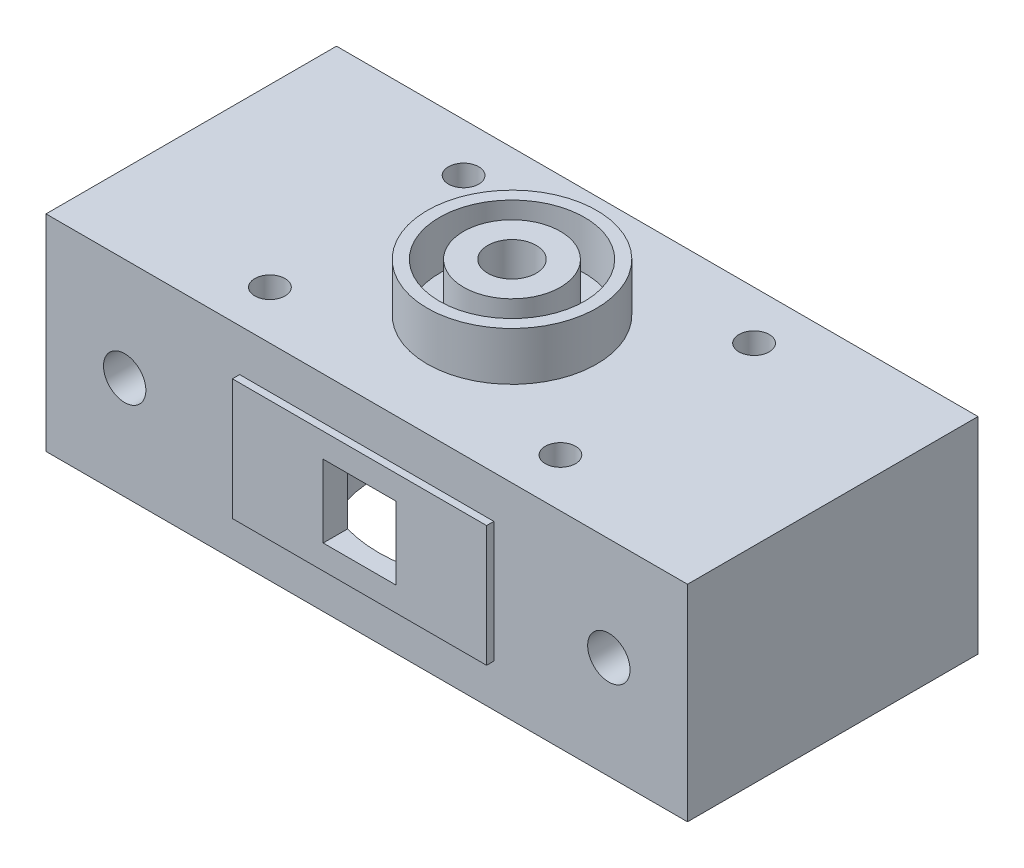
from build123d import *

# Parameters (mm, degrees)
SKETCH_1_R          = 1.75
EXTRUDE_1_DEPTH     = 12
SKETCH_3_R          = 2
CUT_EXTRUDE_1_DEPTH = 18
SKETCH_4_W          = 22.4
SKETCH_4_H          = 14.3
SKETCH_4_W_2        = 6
SKETCH_4_H_2        = 6
EXTRUDE_2_DEPTH     = 1.2
SKETCH_5_W          = 21
SKETCH_5_H          = 10
SKETCH_5_W_2        = 6
SKETCH_5_H_2        = 6
EXTRUDE_3_DEPTH     = 0.6
SKETCH_14_W         = 24.4
SKETCH_14_H         = 23.6
EXTRUDE_6_DEPTH     = 14.3
CUT_EXTRUDE_START   = 2.7
SKETCH_12_R         = 11
CUT_EXTRUDE_6_DEPTH = 14.3
SKETCH_15_W         = 6
SKETCH_15_H         = 6
CUT_EXTRUDE_7_DEPTH = 25.4
SKETCH_6_R          = 7
SKETCH_6_R_2        = 6
SKETCH_6_R_3        = 4
SKETCH_6_R_4        = 2
EXTRUDE_4_DEPTH     = 4
M3X0_51_D           = 2.5
M3X0_51_DEPTH       = 11.5
M3X0_51_TIP         = 0.751075774


with BuildPart() as part:
    # Sketch 1 → Extrude 1 (new body, symmetric)
    with BuildSketch(Plane.XY):
        Polygon((11.2, -17), (11.2, -2.7), (0, -2.7), (0, 0), (26.5, 0), (26.5, -17), align=None)
        with Locations((20, -8.5)):
            Circle(SKETCH_1_R, mode=Mode.SUBTRACT)
    extrude_1 = extrude(amount=EXTRUDE_1_DEPTH, both=True)

    # Mirror 1: Extrude 1 across plane
    add(extrude_1.mirror(Plane(origin=(0, -2.7, -12), x_dir=(0, 0, 1), z_dir=(-1, 0, 0))))

    # Sketch 3 → Cut-Extrude 1 (cut, through all)
    with BuildSketch(Plane(origin=(0, 0, 0), x_dir=(1, 0, 0), z_dir=(0, 1, 0))):
        Circle(SKETCH_3_R)
    extrude(amount=-CUT_EXTRUDE_1_DEPTH, mode=Mode.SUBTRACT)

    # Sketch 4 → Extrude 2 (add)
    with BuildSketch(Plane(origin=(0, 0, -12), x_dir=(-1, 0, 0), z_dir=(0, 0, -1))):
        with Locations((0, -9.85)):
            Rectangle(SKETCH_4_W, SKETCH_4_H)
        with Locations((0, -8.5)):
            Rectangle(SKETCH_4_W_2, SKETCH_4_H_2, mode=Mode.SUBTRACT)
    extrude_2 = extrude(amount=-EXTRUDE_2_DEPTH)

    # Sketch 5 → Extrude 3 (add)
    with BuildSketch(Plane(origin=(0, 0, -12), x_dir=(-1, 0, 0), z_dir=(0, 0, -1))):
        with Locations((0, -8.5)):
            Rectangle(SKETCH_5_W, SKETCH_5_H)
        with Locations((0, -8.5)):
            Rectangle(SKETCH_5_W_2, SKETCH_5_H_2, mode=Mode.SUBTRACT)
    extrude_3 = extrude(amount=EXTRUDE_3_DEPTH)

    # Mirror 2: Extrude 2, Extrude 3 across plane
    add(extrude_2.mirror(Plane.XY))
    add(extrude_3.mirror(Plane.XY))

    # Sketch 14 → Extrude 6 (add)
    with BuildSketch(Plane.XZ.offset(2.7)):
        Rectangle(SKETCH_14_W, SKETCH_14_H)
    extrude(amount=EXTRUDE_6_DEPTH)

    # Sketch 12 → Cut-Extrude 6 (cut)
    with BuildSketch(Plane.XZ.offset(CUT_EXTRUDE_START)):
        Circle(SKETCH_12_R)
    extrude(amount=CUT_EXTRUDE_6_DEPTH, mode=Mode.SUBTRACT)

    # Sketch 15 → Cut-Extrude 7 (cut, through all)
    with BuildSketch(Plane.XY.offset(11.8)):
        with Locations((0, -8.5)):
            Rectangle(SKETCH_15_W, SKETCH_15_H)
    extrude(amount=-CUT_EXTRUDE_7_DEPTH, mode=Mode.SUBTRACT)

    # Sketch 6 → Extrude 4 (add)
    with BuildSketch(Plane(origin=(0, 0, 0), x_dir=(1, 0, 0), z_dir=(0, 1, 0))):
        Circle(SKETCH_6_R)
        Circle(SKETCH_6_R_2, mode=Mode.SUBTRACT)
        Circle(SKETCH_6_R_3)
        Circle(SKETCH_6_R_4, mode=Mode.SUBTRACT)
    extrude(amount=EXTRUDE_4_DEPTH)

    # M3x0.51
    with Locations(Plane(origin=(0, 0, 0), x_dir=(1, 0, 0), z_dir=(0, 1, 0))):
        with Locations((12, 8), (12, -8), (-12, -8), (-12, 8)):
            Hole(M3X0_51_D / 2, depth=M3X0_51_DEPTH)
            with Locations((0, 0, -(M3X0_51_DEPTH + M3X0_51_TIP / 2))):  # 118° drill point
                Cone(0, M3X0_51_D / 2, M3X0_51_TIP, mode=Mode.SUBTRACT)


solid = part.part
